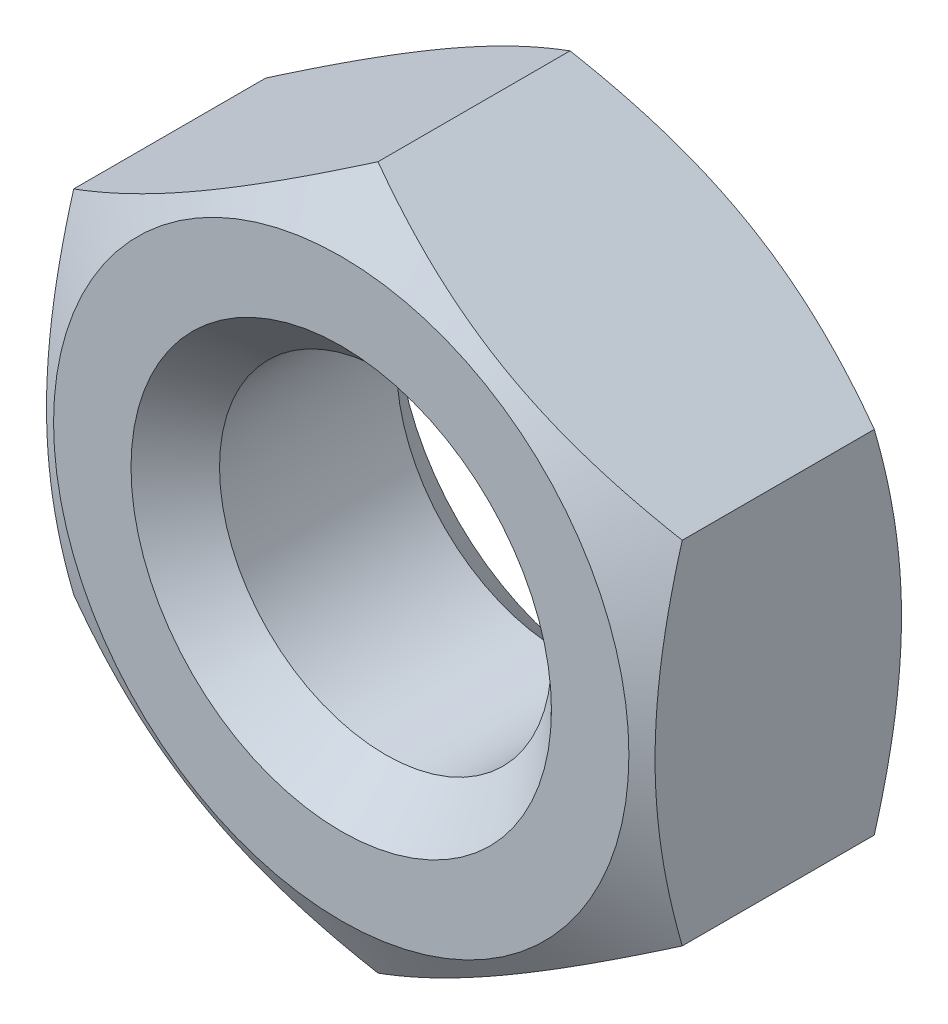
from build123d import *

# Parameters (mm, degrees)
SKETCH_1_W               = 4
SKETCH_1_H               = 2.4
SKETCH_2_OUTSIDE_W       = 12.314
SKETCH_2_OUTSIDE_H       = 12.314
CUT_EXTRUDE_1_DEPTH      = 2.4
SKETCH_3_R               = 1.5
CUT_EXTRUDE_2_DEPTH      = 1
CUT_EXTRUDE_2_DEPTH_BACK = 3.4
CHAMFER_1_SIZE           = 0.4


with BuildPart() as part:
    # Эскиз1 → Повернуть1 (revolve)
    with BuildSketch(Plane(origin=(0, 0, 0), x_dir=(1, 0, 0), z_dir=(0, 1, 0))):
        with Locations((-2, 1.2)):
            Rectangle(SKETCH_1_W, SKETCH_1_H)
    revolve(axis=Axis((0, 0, 0), (0, 0, -1)))

    # Эскиз2 outside → Вырез-Вытянуть1 (cut)
    with BuildSketch(Plane.XY):
        Rectangle(SKETCH_2_OUTSIDE_W, SKETCH_2_OUTSIDE_H)
        Polygon((2.75, -1.58771324), (2.75, 1.58771324), (0, 3.175426481), (-2.75, 1.58771324), (-2.75, -1.58771324), (0, -3.175426481), align=None, mode=Mode.SUBTRACT)
    extrude(amount=-CUT_EXTRUDE_1_DEPTH, mode=Mode.SUBTRACT)

    # Эскиз3 → Вырез-Вытянуть2 (cut, two sides)
    with BuildSketch(Plane.XY) as cut_extrude_2_sk:
        Circle(SKETCH_3_R)
    extrude(amount=CUT_EXTRUDE_2_DEPTH, mode=Mode.SUBTRACT)
    extrude(cut_extrude_2_sk.sketch, amount=-CUT_EXTRUDE_2_DEPTH_BACK, mode=Mode.SUBTRACT)

    # Эскиз4 → Вырез-Повернуть1 (revolve, cut)
    with BuildSketch(Plane(origin=(0, 0, 0), x_dir=(0, 0, -1), z_dir=(1, 0, 0))):
        Polygon((0, 2.6), (0.332222633, 3.175426481), (0, 3.175426481), align=None)
        Polygon((2.4, 2.6), (2.067777367, 3.175426481), (2.4, 3.175426481), align=None)
    revolve(axis=Axis((0, 0, 0), (0, 0, -1)), mode=Mode.SUBTRACT)

    # Фаска1
    chamfer_1_edges = [part.edges().sort_by_distance(p)[0] for p in [
        (-1.5, 0, -2.4),
        (-1.5, 0, 0),
    ]]
    chamfer(chamfer_1_edges, length=CHAMFER_1_SIZE)


solid = part.part
